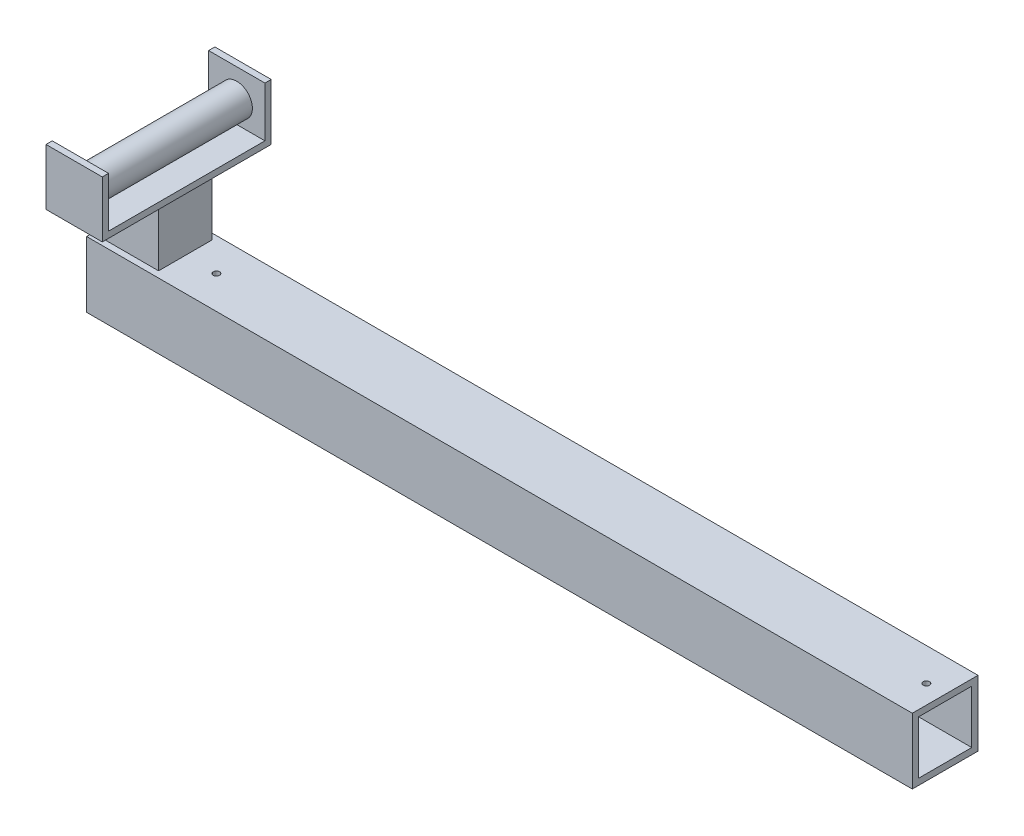
from build123d import *

# Parameters (mm, degrees)
SKETCH1_W           = 1676.4
SKETCH1_H           = 133.35
BOSS_EXTRUDE1_DEPTH = 133.35
SKETCH2_W           = 107.95
SKETCH2_H           = 107.95
CUT_EXTRUDE1_DEPTH  = 1524
SKETCH3_W           = 107.95
SKETCH3_H           = 107.95
BOSS_EXTRUDE2_DEPTH = 114.3
SKETCH4_W           = 114.3
SKETCH4_H           = 342.9
BOSS_EXTRUDE3_DEPTH = 12.7
SKETCH5_W           = 114.3
SKETCH5_H           = 12.7
BOSS_EXTRUDE4_DEPTH = 101.6
SKETCH6_R           = 31.75
BOSS_EXTRUDE5_DEPTH = 317.5
SKETCH7_R           = 6.35
CUT_EXTRUDE2_DEPTH  = 12.7


with BuildPart() as part:
    # Sketch1 → Boss-Extrude1 (new body)
    with BuildSketch(Plane.XY):
        with Locations((838.2, 66.675)):
            Rectangle(SKETCH1_W, SKETCH1_H)
    extrude(amount=BOSS_EXTRUDE1_DEPTH)

    # Sketch2 → Cut-Extrude1 (cut)
    with BuildSketch(Plane(origin=(1676.4, 0, 0), x_dir=(0, 0, -1), z_dir=(1, 0, 0))):
        with Locations((-66.675, 66.675)):
            Rectangle(SKETCH2_W, SKETCH2_H)
    extrude(amount=-CUT_EXTRUDE1_DEPTH, mode=Mode.SUBTRACT)

    # Sketch3 → Boss-Extrude2 (add)
    with BuildSketch(Plane(origin=(0, 133.35, 0), x_dir=(1, 0, 0), z_dir=(0, 1, 0))):
        with Locations((79.375, -66.675)):
            Rectangle(SKETCH3_W, SKETCH3_H)
    extrude(amount=BOSS_EXTRUDE2_DEPTH)

    # Sketch4 → Boss-Extrude3 (add)
    with BuildSketch(Plane(origin=(0, 247.65, 0), x_dir=(1, 0, 0), z_dir=(0, 1, 0))):
        with Locations((82.55, -69.85)):
            Rectangle(SKETCH4_W, SKETCH4_H)
    extrude(amount=BOSS_EXTRUDE3_DEPTH)

    # Sketch5 → Boss-Extrude4 (add)
    with BuildSketch(Plane(origin=(0, 260.35, 0), x_dir=(1, 0, 0), z_dir=(0, 1, 0))):
        with Locations((82.55, 95.25)):
            Rectangle(SKETCH5_W, SKETCH5_H)
        with Locations((82.55, -234.95)):
            Rectangle(SKETCH5_W, SKETCH5_H)
    extrude(amount=BOSS_EXTRUDE4_DEPTH)

    # Sketch6 → Boss-Extrude5 (add)
    with BuildSketch(Plane.XY.offset(-88.9)):
        with Locations((82.55, 304.8)):
            Circle(SKETCH6_R)
    extrude(amount=BOSS_EXTRUDE5_DEPTH)

    # Sketch7 → Cut-Extrude2 (cut)
    with BuildSketch(Plane(origin=(0, 133.35, 0), x_dir=(1, 0, 0), z_dir=(0, 1, 0))):
        with Locations((196.85, -66.675)):
            Circle(SKETCH7_R)
        with Locations((1638.3, -66.675)):
            Circle(SKETCH7_R)
    extrude(amount=-CUT_EXTRUDE2_DEPTH, mode=Mode.SUBTRACT)


solid = part.part
